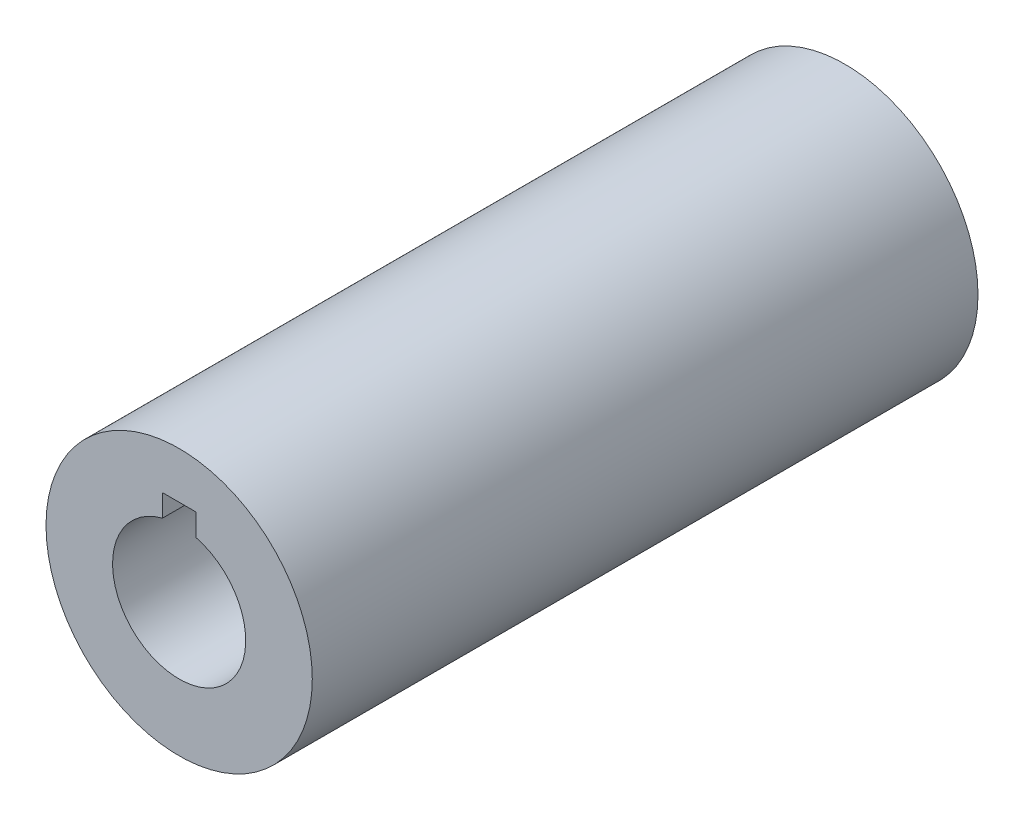
from build123d import *

# Parameters (mm, degrees)
SKETCH1_R           = 20
BOSS_EXTRUDE1_DEPTH = 50


with BuildPart() as part:
    # Sketch1 → Boss-Extrude1 (new body, symmetric)
    with BuildSketch(Plane.XY):
        Circle(SKETCH1_R)
        with BuildLine():
            Line((2.5, 9.682458366), (2.5, 13))
            Line((2.5, 13), (-2.5, 13))
            Line((-2.5, 13), (-2.5, 9.682458366))
            ThreePointArc((-2.5, 9.682458366), (0, -10), (2.5, 9.682458366))
        make_face(mode=Mode.SUBTRACT)
    extrude(amount=BOSS_EXTRUDE1_DEPTH, both=True)


solid = part.part
